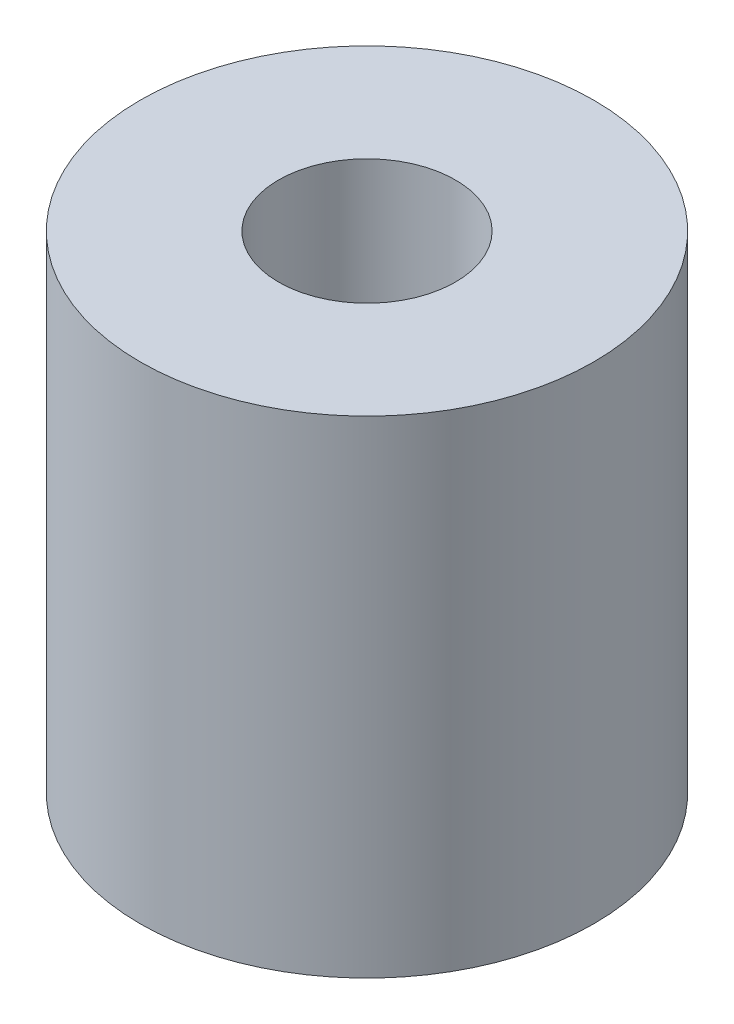
from build123d import *

# Parameters (mm, degrees)
SKETCH1_R           = 41
SKETCH1_R_2         = 16
BOSS_EXTRUDE1_DEPTH = 88


with BuildPart() as part:
    # Sketch1 → Boss-Extrude1 (new body)
    with BuildSketch(Plane(origin=(0, 0, 0), x_dir=(1, 0, 0), z_dir=(0, 1, 0))):
        Circle(SKETCH1_R)
        Circle(SKETCH1_R_2, mode=Mode.SUBTRACT)
    extrude(amount=BOSS_EXTRUDE1_DEPTH)


solid = part.part
